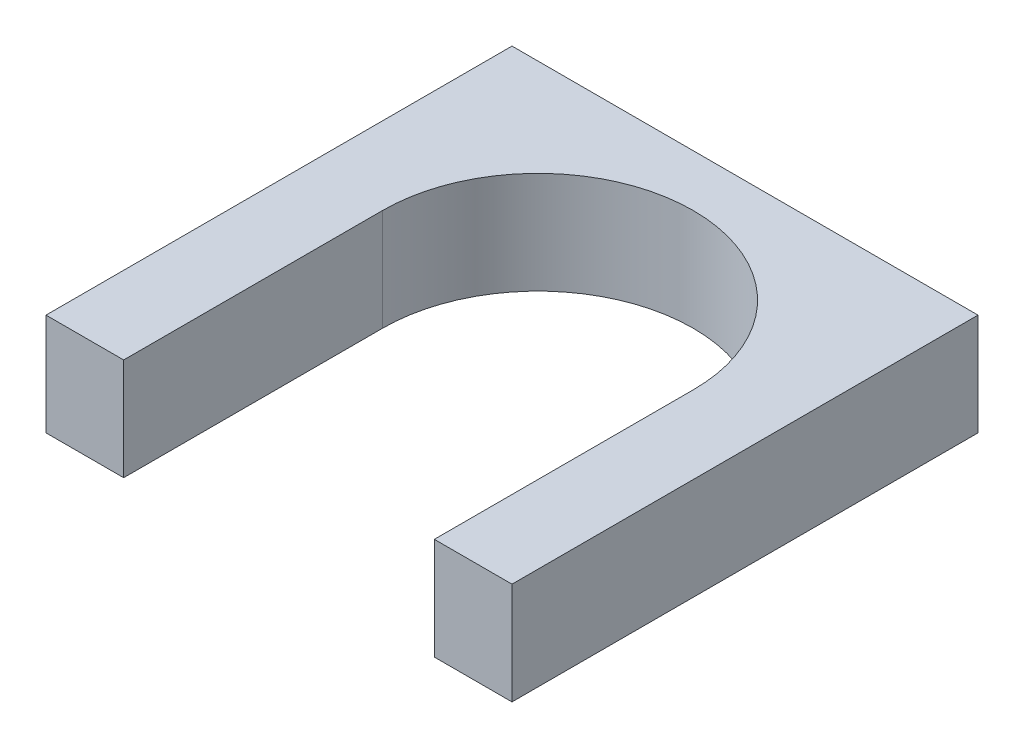
from build123d import *

# Parameters (mm, degrees)
ESQUISSE1_W             = 90
ESQUISSE1_H             = 19.7
BOSS_EXTRU_1_DEPTH      = 90
ENL_V_MAT_EXTRU_1_DEPTH = 30


with BuildPart() as part:
    # Esquisse1 → Boss.-Extru.1 (new body)
    with BuildSketch(Plane.XY):
        with Locations((-4.101935153, 9.85)):
            Rectangle(ESQUISSE1_W, ESQUISSE1_H)
    extrude(amount=BOSS_EXTRU_1_DEPTH)

    # Esquisse2 → Enlèv. mat.-Extru.1 (cut)
    with BuildSketch(Plane(origin=(0, 19.7, 0), x_dir=(1, 0, 0), z_dir=(0, 1, 0))):
        with BuildLine():
            Line((-34.101935153, -40), (-34.101935153, -90))
            Line((-34.101935153, -90), (25.898064847, -90))
            Line((25.898064847, -90), (25.898064847, -40))
            ThreePointArc((25.898064847, -40), (-4.101935153, -10), (-34.101935153, -40))
        make_face()
    extrude(amount=-ENL_V_MAT_EXTRU_1_DEPTH, mode=Mode.SUBTRACT)


solid = part.part
